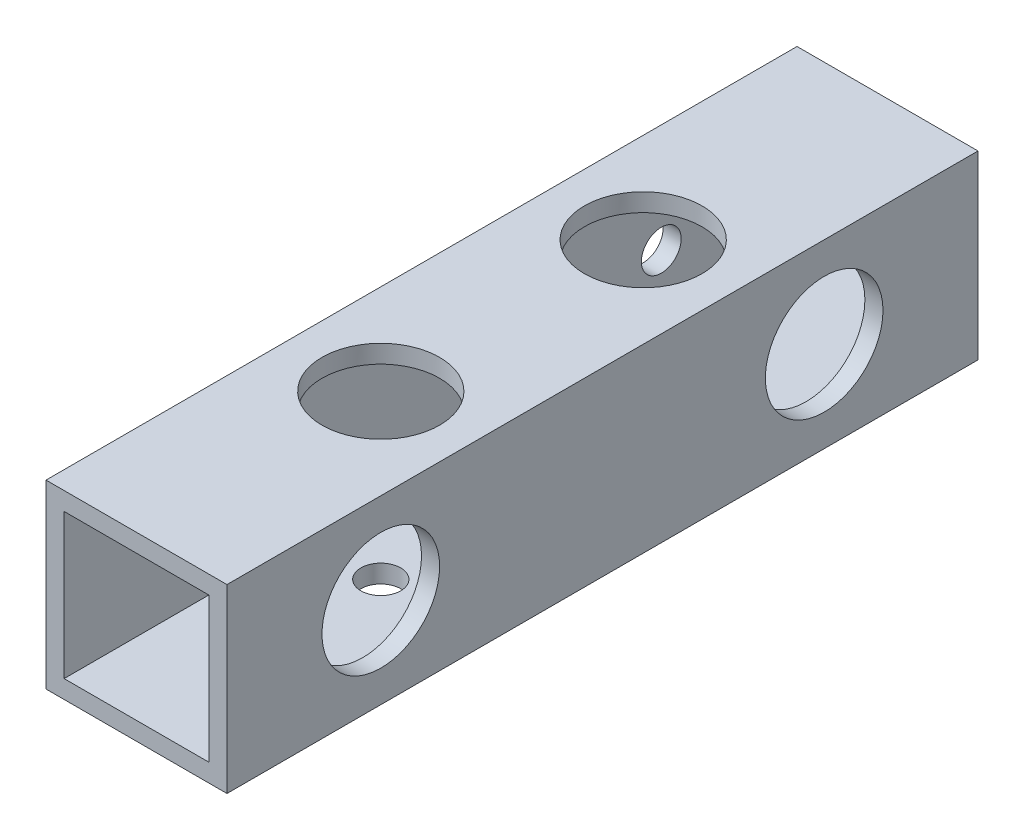
from build123d import *

# Parameters (mm, degrees)
SKETCH_1_W               = 20
SKETCH_1_H               = 20
SKETCH_1_W_2             = 16
SKETCH_1_H_2             = 16
EXTRUDE_1_DEPTH          = 83
SKETCH_2_R               = 2.2
CUT_EXTRUDE_1_DEPTH      = 83
SKETCH_3_R               = 6.5
CUT_EXTRUDE_2_DEPTH      = 3
SKETCH_4_R               = 2.2
CUT_EXTRUDE_3_DEPTH      = 1
CUT_EXTRUDE_3_DEPTH_BACK = 21
SKETCH_5_R               = 6.5
CUT_EXTRUDE_4_DEPTH      = 3


with BuildPart() as part:
    # ｽｹｯﾁ1 → ﾎﾞｽ - 押し出し1 (new body)
    with BuildSketch(Plane.XY):
        Rectangle(SKETCH_1_W, SKETCH_1_H)
        Rectangle(SKETCH_1_W_2, SKETCH_1_H_2, mode=Mode.SUBTRACT)
    extrude(amount=EXTRUDE_1_DEPTH)

    # ｽｹｯﾁ2 → ｶｯﾄ - 押し出し1 (cut)
    with BuildSketch(Plane(origin=(10, 0, 0), x_dir=(0, 0, -1), z_dir=(1, 0, 0))):
        with Locations((-66, 0)):
            Circle(SKETCH_2_R)
        with Locations((-17, 0)):
            Circle(SKETCH_2_R)
    extrude(amount=-CUT_EXTRUDE_1_DEPTH, mode=Mode.SUBTRACT)

    # ｽｹｯﾁ3 → ｶｯﾄ - 押し出し2 (cut)
    with BuildSketch(Plane(origin=(10, 0, 0), x_dir=(0, 0, -1), z_dir=(1, 0, 0))):
        with Locations((-66, 0)):
            Circle(SKETCH_3_R)
        with Locations((-17, 0)):
            Circle(SKETCH_3_R)
    extrude(amount=-CUT_EXTRUDE_2_DEPTH, mode=Mode.SUBTRACT)

    # ｽｹｯﾁ4 → ｶｯﾄ - 押し出し3 (cut, two sides)
    with BuildSketch(Plane.XZ.offset(10)) as cut_extrude_3_sk:
        with Locations((0, 56)):
            Circle(SKETCH_4_R)
        with Locations((0, 27)):
            Circle(SKETCH_4_R)
    extrude(amount=CUT_EXTRUDE_3_DEPTH, mode=Mode.SUBTRACT)
    extrude(cut_extrude_3_sk.sketch, amount=-CUT_EXTRUDE_3_DEPTH_BACK, mode=Mode.SUBTRACT)

    # ｽｹｯﾁ5 → ｶｯﾄ - 押し出し4 (cut)
    with BuildSketch(Plane(origin=(0, 10, 0), x_dir=(1, 0, 0), z_dir=(0, 1, 0))):
        with Locations((0, -56)):
            Circle(SKETCH_5_R)
        with Locations((0, -27)):
            Circle(SKETCH_5_R)
    extrude(amount=-CUT_EXTRUDE_4_DEPTH, mode=Mode.SUBTRACT)


solid = part.part
